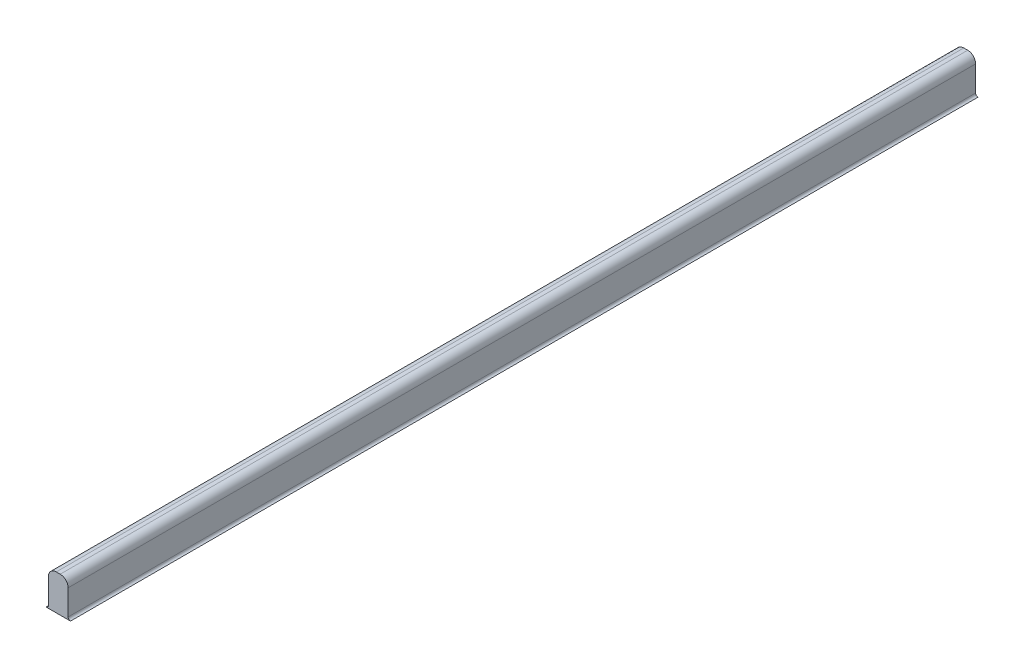
from build123d import *

# Parameters (mm, degrees)
RESSALTO_EXTRUS_O1_DEPTH = 115
FILETE1_R                = 1


with BuildPart() as part:
    # Esboço1 → Ressalto-extrusão1 (new body)
    with BuildSketch(Plane.XY):
        Polygon((-5.5, -1.198132677), (-5.5, -1.5), (-4.25, -1.5), (-4.25, 3), (-5.5, 3), align=None)
        with BuildLine():
            Line((-5.801867323, -1.5), (-5.5, -1.5))
            Line((-5.5, -1.5), (-5.5, -1.198132677))
            ThreePointArc((-5.5, -1.198132677), (-5.588414892, -1.411585108), (-5.801867323, -1.5))
        make_face()
        Polygon((-4.25, 3), (-4.25, -1.5), (-3, -1.5), (-3, -1.198132677), (-3, 3), align=None)
        with BuildLine():
            Line((-3, -1.198132677), (-3, -1.5))
            Line((-3, -1.5), (-2.698132677, -1.5))
            ThreePointArc((-2.698132677, -1.5), (-2.911585108, -1.411585108), (-3, -1.198132677))
        make_face()
    extrude(amount=RESSALTO_EXTRUS_O1_DEPTH)

    # Filete1
    filete1_edges = [part.edges().sort_by_distance(p)[0] for p in [
        (-3, 3, 57.5),
        (-5.5, 3, 57.5),
    ]]
    fillet(filete1_edges, radius=FILETE1_R)


solid = part.part
